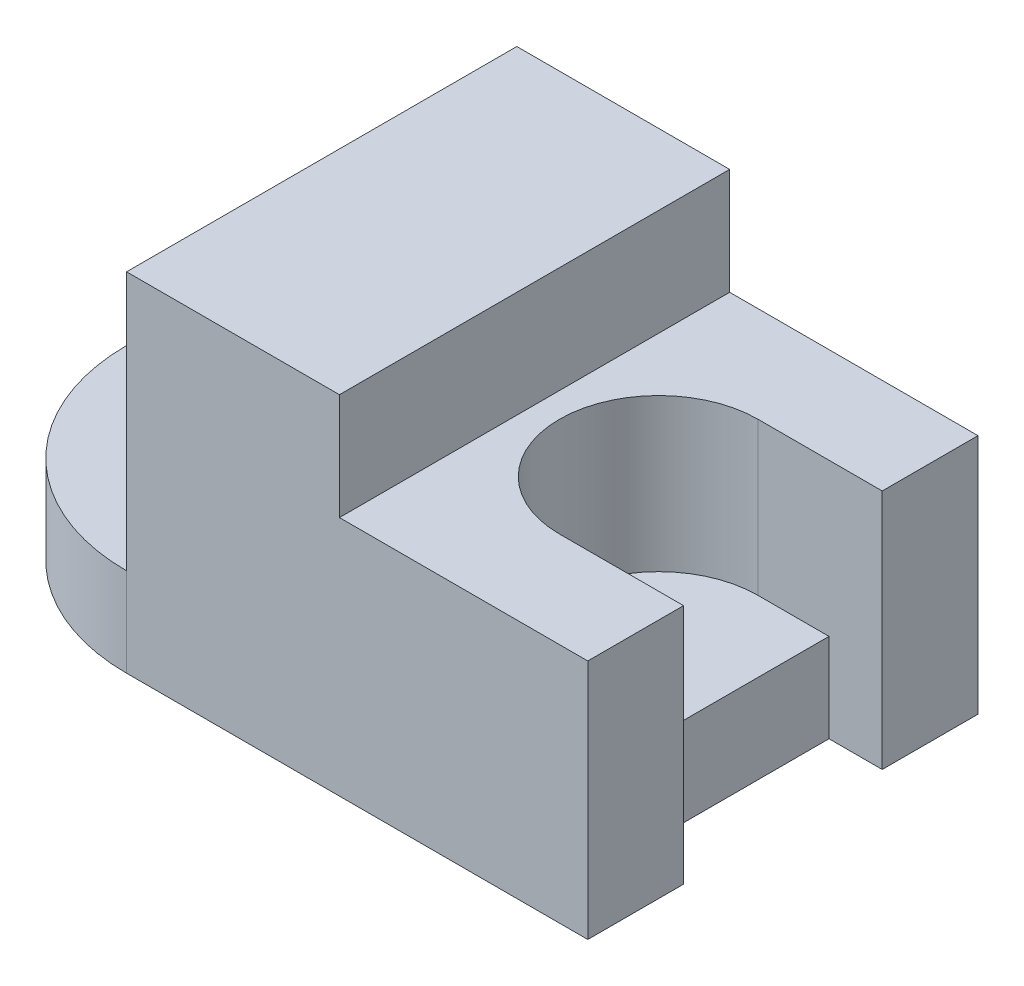
from build123d import *

# Parameters (mm, degrees)
SKETCH1_R           = 15
BOSS_EXTRUDE1_DEPTH = 25
SKETCH3_W           = 130
SKETCH3_H           = 110
BOSS_EXTRUDE2_DEPTH = 43
SKETCH4_W           = 60
SKETCH4_H           = 110
BOSS_EXTRUDE3_DEPTH = 30
SKETCH5_W           = 42
SKETCH5_H           = 28
CUT_REVOLVE1_ANGLE  = 180
SKETCH6_W           = 56
SKETCH6_H           = 68
CUT_EXTRUDE1_DEPTH  = 15
CUT_EXTRUDE2_DEPTH  = 43


with BuildPart() as part:
    # Sketch1 → Boss-Extrude1 (new body)
    with BuildSketch(Plane(origin=(0, 0, 0), x_dir=(1, 0, 0), z_dir=(0, 1, 0))):
        with BuildLine():
            Line((0, 55), (130, 55))
            Line((130, 55), (130, -55))
            Line((130, -55), (0, -55))
            ThreePointArc((0, -55), (-55, 0), (0, 55))
        make_face()
        Circle(SKETCH1_R, mode=Mode.SUBTRACT)
    extrude(amount=BOSS_EXTRUDE1_DEPTH)

    # Sketch3 → Boss-Extrude2 (add)
    with BuildSketch(Plane(origin=(0, 25, 0), x_dir=(1, 0, 0), z_dir=(0, 1, 0))):
        with Locations((65, 0)):
            Rectangle(SKETCH3_W, SKETCH3_H)
    extrude(amount=BOSS_EXTRUDE2_DEPTH)

    # Sketch4 → Boss-Extrude3 (add)
    with BuildSketch(Plane(origin=(0, 68, 0), x_dir=(1, 0, 0), z_dir=(0, 1, 0))):
        with Locations((30, 0)):
            Rectangle(SKETCH4_W, SKETCH4_H)
    extrude(amount=BOSS_EXTRUDE3_DEPTH)

    # Sketch5 → Cut-Revolve1 (revolve, cut)
    with BuildSketch(Plane.ZY):
        with Locations((-21, 39)):
            Rectangle(SKETCH5_W, SKETCH5_H)
    revolve(axis=Axis((0, 0, 0), (0, -1, 0)), revolution_arc=CUT_REVOLVE1_ANGLE, mode=Mode.SUBTRACT)

    # Sketch6 → Cut-Extrude1 (cut)
    with BuildSketch(Plane(origin=(130, 0, 0), x_dir=(0, 0, -1), z_dir=(1, 0, 0))):
        with Locations((0, 34)):
            Rectangle(SKETCH6_W, SKETCH6_H)
    extrude(amount=-CUT_EXTRUDE1_DEPTH, mode=Mode.SUBTRACT)

    # Sketch7 → Cut-Extrude2 (cut)
    with BuildSketch(Plane(origin=(0, 68, 0), x_dir=(1, 0, 0), z_dir=(0, 1, 0))):
        with BuildLine():
            Line((115, 28), (95, 28))
            ThreePointArc((95, 28), (67, 0), (95, -28))
            Line((95, -28), (115, -28))
            Line((115, -28), (115, 28))
        make_face()
    extrude(amount=-CUT_EXTRUDE2_DEPTH, mode=Mode.SUBTRACT)


solid = part.part
